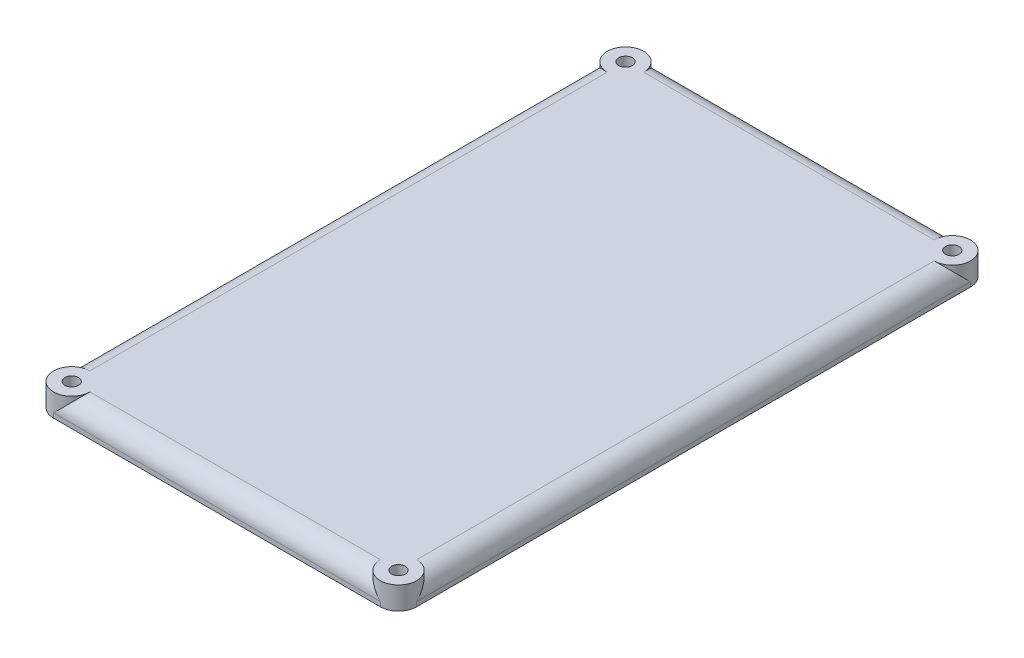
from build123d import *

# Parameters (mm, degrees)
SKETCH1_W           = 50.8
SKETCH1_H           = 82.55
BOSS_EXTRUDE1_DEPTH = 3.175
FILLET1_R           = 2.54
SKETCH2_R           = 2.54
CUT_EXTRUDE1_DEPTH  = 97.980529618
SKETCH2_2_R         = 2.54
BOSS_EXTRUDE2_DEPTH = 3.175
SKETCH3_R           = 0.9525
CUT_EXTRUDE2_DEPTH  = 97.980529618


with BuildPart() as part:
    # Sketch1 → Boss-Extrude1 (new body)
    with BuildSketch(Plane(origin=(0, 0, 0), x_dir=(1, 0, 0), z_dir=(0, 1, 0))):
        with Locations((25.4, -41.275)):
            Rectangle(SKETCH1_W, SKETCH1_H)
    extrude(amount=BOSS_EXTRUDE1_DEPTH)

    # Fillet1
    fillet1_edges = [part.edges().sort_by_distance(p)[0] for p in [
        (0, 1.5875, 0),
        (50.8, 1.5875, 0),
        (25.4, 3.175, 0),
        (50.8, 3.175, 41.275),
        (50.8, 1.5875, 82.55),
        (0, 1.5875, 82.55),
        (0, 3.175, 41.275),
        (25.4, 3.175, 82.55),
    ]]
    fillet(fillet1_edges, radius=FILLET1_R)

    # Sketch2 → Cut-Extrude1 (cut, through all)
    with BuildSketch(Plane(origin=(0, 3.175, 0), x_dir=(1, 0, 0), z_dir=(0, 1, 0))):
        with Locations((48.26, -80.01)):
            Circle(SKETCH2_R)
        with Locations((2.54, -80.01)):
            Circle(SKETCH2_R)
        with Locations((2.54, -2.54)):
            Circle(SKETCH2_R)
        with Locations((48.26, -2.54)):
            Circle(SKETCH2_R)
    extrude(amount=-CUT_EXTRUDE1_DEPTH, mode=Mode.SUBTRACT)

    # Sketch2_2 → Boss-Extrude2 (add)
    with BuildSketch(Plane(origin=(0, 3.175, 0), x_dir=(1, 0, 0), z_dir=(0, 1, 0))):
        with Locations((48.26, -80.01)):
            Circle(SKETCH2_2_R)
        with Locations((2.54, -80.01)):
            Circle(SKETCH2_2_R)
        with Locations((2.54, -2.54)):
            Circle(SKETCH2_2_R)
        with Locations((48.26, -2.54)):
            Circle(SKETCH2_2_R)
    extrude(amount=-BOSS_EXTRUDE2_DEPTH)

    # Sketch3 → Cut-Extrude2 (cut, through all)
    with BuildSketch(Plane(origin=(0, 3.175, 0), x_dir=(1, 0, 0), z_dir=(0, 1, 0))):
        with Locations((2.54, -2.54)):
            Circle(SKETCH3_R)
        with Locations((48.26, -2.54)):
            Circle(SKETCH3_R)
        with Locations((2.54, -80.01)):
            Circle(SKETCH3_R)
        with Locations((48.26, -80.01)):
            Circle(SKETCH3_R)
    extrude(amount=-CUT_EXTRUDE2_DEPTH, mode=Mode.SUBTRACT)


solid = part.part
